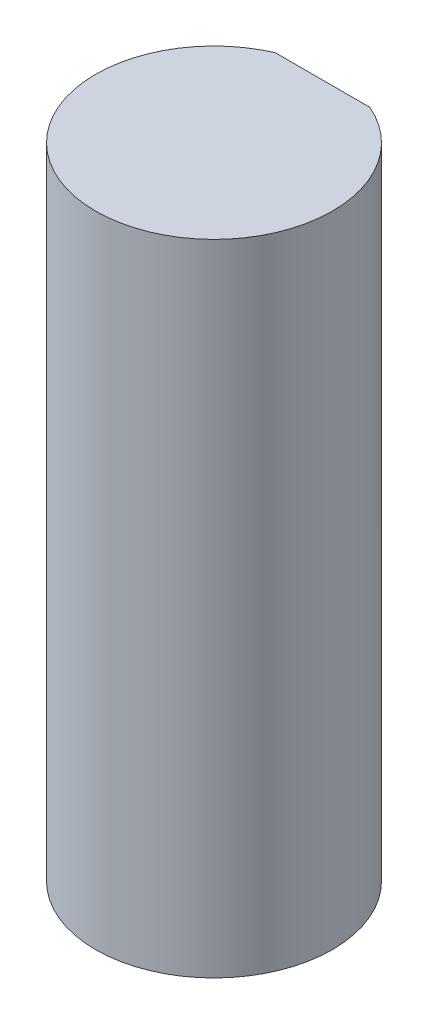
from build123d import *

# Parameters (mm, degrees)
SKETCH3_R           = 3
BOSS_EXTRUDE2_DEPTH = 16.2
CUT_EXTRUDE1_DEPTH  = 12


with BuildPart() as part:
    # Sketch3 → Boss-Extrude2 (new body)
    with BuildSketch(Plane(origin=(0, 0, 0), x_dir=(1, 0, 0), z_dir=(0, 1, 0))):
        Circle(SKETCH3_R)
    extrude(amount=BOSS_EXTRUDE2_DEPTH)

    # Sketch4 → Cut-Extrude1 (cut)
    with BuildSketch(Plane(origin=(0, 16.2, 0), x_dir=(1, 0, 0), z_dir=(0, 1, 0))):
        with BuildLine():
            Line((-1.198957881, 2.75), (1.198957881, 2.75))
            ThreePointArc((1.198957881, 2.75), (0, 3), (-1.198957881, 2.75))
        make_face()
    extrude(amount=-CUT_EXTRUDE1_DEPTH, mode=Mode.SUBTRACT)


solid = part.part
